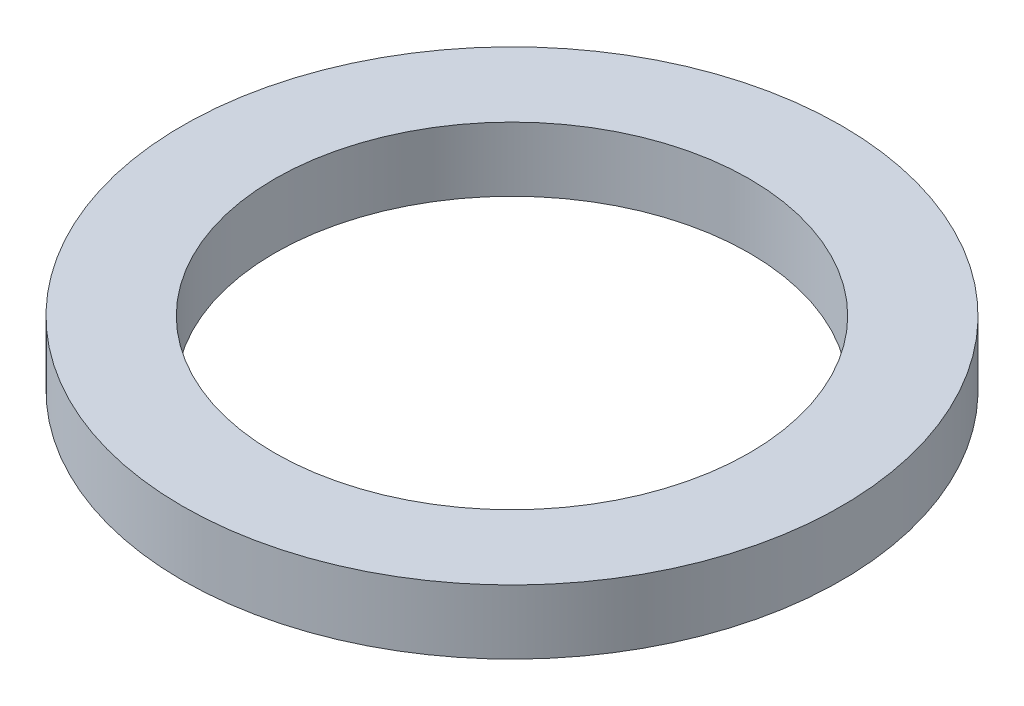
from build123d import *

# Parameters (mm, degrees)
SKETCH1_R           = 5.9
SKETCH1_R_2         = 4.25
BOSS_EXTRUDE1_DEPTH = 1.15


with BuildPart() as part:
    # Sketch1 → Boss-Extrude1 (new body)
    with BuildSketch(Plane(origin=(0, 0, 0), x_dir=(1, 0, 0), z_dir=(0, 1, 0))):
        Circle(SKETCH1_R)
        Circle(SKETCH1_R_2, mode=Mode.SUBTRACT)
    extrude(amount=BOSS_EXTRUDE1_DEPTH)


solid = part.part
